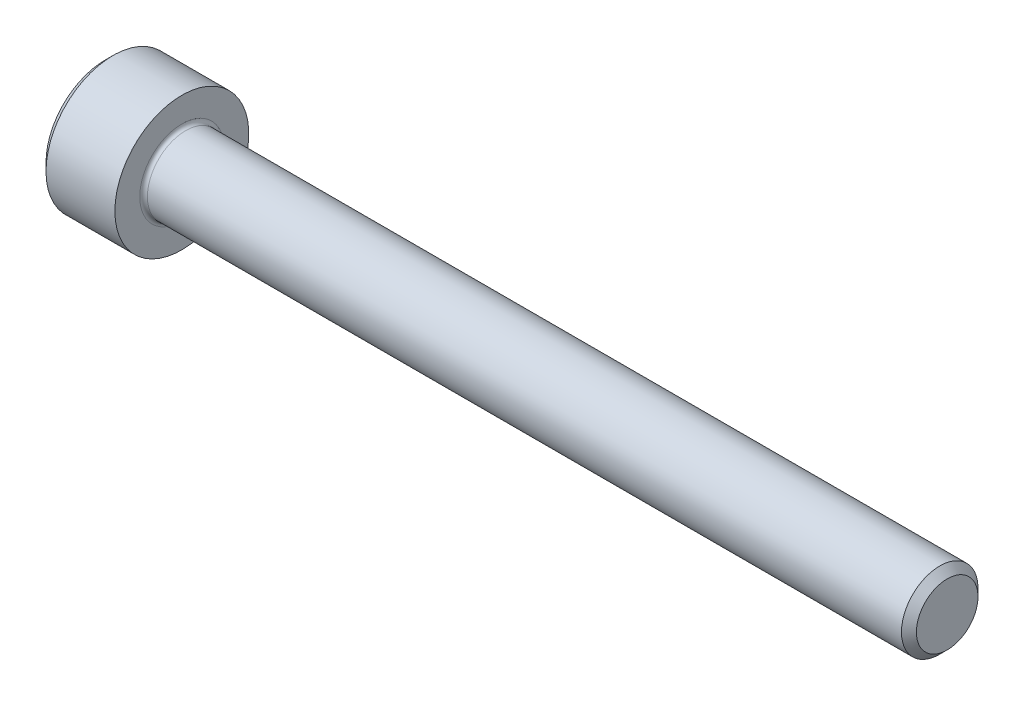
from build123d import *

# Parameters (mm, degrees)
FILLET1_R   = 0.2
HEX_2_DEPTH = 2


with BuildPart() as part:
    # BodySke → Base-Revolve (revolve)
    with BuildSketch(Plane.XY):
        Polygon((0, 0), (0, 3.1), (0.4, 3.5), (4, 3.5), (4, 2), (43.61, 2), (44, 1.61), (44, 0), align=None)
    revolve(axis=Axis((-31.75, 0, 0), (1, 0, 0)))

    # Fillet1
    fillet1_edges = [part.edges().sort_by_distance(p)[0] for p in [
        (4, -2, 0),
    ]]
    fillet(fillet1_edges, radius=FILLET1_R)

    # Sketch2 → Hex-PreBroach (revolve, cut)
    with BuildSketch(Plane.XY):
        Polygon((0, 1.5355), (2, 1.5355), (2.886521338, 0), (0, 0), align=None)
    revolve(axis=Axis((0, 0, 0), (1, 0, 0)), mode=Mode.SUBTRACT)

    # Sketch3 → Hex 2 (cut)
    with BuildSketch(Plane(origin=(0, 0, 0), x_dir=(0, 0.5, 0.866025404), z_dir=(-1, 0, 0))):
        Polygon((0.886521338, 1.5355), (-0.886521338, 1.5355), (-1.773042677, 0), (-0.886521338, -1.5355), (0.886521338, -1.5355), (1.773042677, 0), align=None)
    extrude(amount=-HEX_2_DEPTH, mode=Mode.SUBTRACT)


solid = part.part
